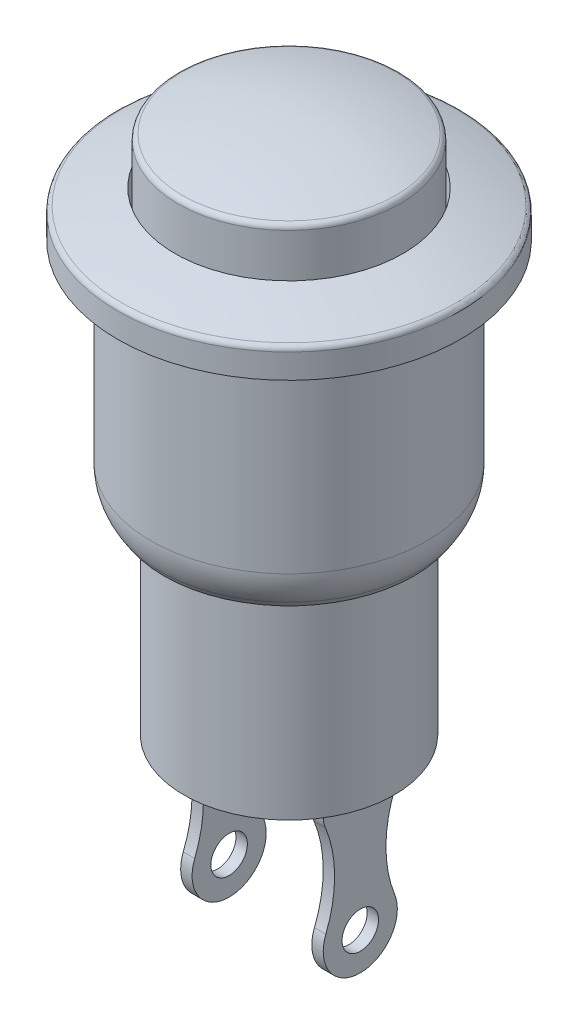
from build123d import *

# Parameters (mm, degrees)
CONG_1_R                = 0.2
CONG_2_R                = 0.2
CHANFREIN1_SIZE         = 0.7
CHANFREIN1_SIZE2        = 0.454585315
CONG_3_R                = 2
ESQUISSE2_W             = 0.4
ESQUISSE2_H             = 2.6
BOSS_EXTRU_1_DEPTH      = 6
ESQUISSE3_R             = 0.64
ENL_V_MAT_EXTRU_1_DEPTH = 6
CONG_4_R                = 1


with BuildPart() as part:
    # Esquisse1 → Révolution1 (revolve)
    with BuildSketch(Plane.XY):
        with BuildLine():
            Line((0, 18.8), (0, 0))
            Line((0, 0), (3.69, 0))
            Line((3.69, 0), (3.69, 7))
            Line((3.69, 7), (4.84, 7))
            Line((4.84, 7), (4.84, 15))
            Line((4.84, 15), (6.01, 15))
            Line((6.01, 15), (6.01, 16))
            ThreePointArc((6.01, 16), (5.013982948, 16.330092875), (4, 16.6))
            Line((4, 16.6), (4, 15.013190638))
            Line((4, 15.013190638), (3.89, 15.013190638))
            Line((3.89, 15.013190638), (3.89, 18.2))
            ThreePointArc((3.89, 18.2), (1.968000254, 18.649118314), (0, 18.8))
        make_face()
    revolve(axis=Axis((0, 0, 0), (0, 1, 0)))

    # Congé1
    cong_1_edges = [part.edges().sort_by_distance(p)[0] for p in [
        (-3.89, 18.2, 0),
    ]]
    fillet(cong_1_edges, radius=CONG_1_R)

    # Congé2
    cong_2_edges = [part.edges().sort_by_distance(p)[0] for p in [
        (-6.01, 16, 0),
    ]]
    fillet(cong_2_edges, radius=CONG_2_R)

    # Chanfrein1
    chanfrein1_edges = [part.edges().sort_by_distance(p)[0] for p in [
        (-4.84, 7, 0),
    ]]
    chanfrein1_side = [part.faces().sort_by_distance(p)[0] for p in [
        (-4.84, 11, 0),
    ]]
    chamfer(chanfrein1_edges, length=CHANFREIN1_SIZE, length2=CHANFREIN1_SIZE2, reference=chanfrein1_side[0])

    # Congé3
    cong_3_edges = [part.edges().sort_by_distance(p)[0] for p in [
        (-4.84, 7.7, 0),
    ]]
    fillet(cong_3_edges, radius=CONG_3_R)

    # Esquisse2 → Boss.-Extru.1 (add)
    with BuildSketch(Plane.XZ):
        with Locations((2.3, 0)):
            Rectangle(ESQUISSE2_W, ESQUISSE2_H)
        with Locations((-2.3, 0)):
            Rectangle(ESQUISSE2_W, ESQUISSE2_H)
    extrude(amount=BOSS_EXTRU_1_DEPTH)

    # Esquisse3 → Enlèv. mat.-Extru.1 (cut)
    with BuildSketch(Plane.ZY.offset(2.5)):
        with Locations((0, -4.7)):
            Circle(ESQUISSE3_R)
        with BuildLine():
            Line((-1.3, -0.8), (-4.192462756, -0.8))
            Line((-4.192462756, -0.8), (-4.192462756, -7.475627282))
            Line((-4.192462756, -7.475627282), (5.572809524, -7.57510374))
            Line((5.572809524, -7.57510374), (5.225347222, -0.8))
            Line((5.225347222, -0.8), (1.3, -0.8))
            ThreePointArc((1.3, -0.8), (0.901580438, -2.499750503), (1.207561262, -4.218548238))
            ThreePointArc((1.207561262, -4.218548238), (0, -6), (-1.207561262, -4.218548238))
            ThreePointArc((-1.207561262, -4.218548238), (-0.901580438, -2.499750503), (-1.3, -0.8))
        make_face()
    extrude(amount=-ENL_V_MAT_EXTRU_1_DEPTH, mode=Mode.SUBTRACT)

    # Congé4
    cong_4_edges = [part.edges().sort_by_distance(p)[0] for p in [
        (-2.3, -0.8, -1.3),
        (2.3, -0.8, -1.3),
        (2.3, -0.8, 1.3),
        (-2.3, -0.8, 1.3),
    ]]
    fillet(cong_4_edges, radius=CONG_4_R)


solid = part.part
